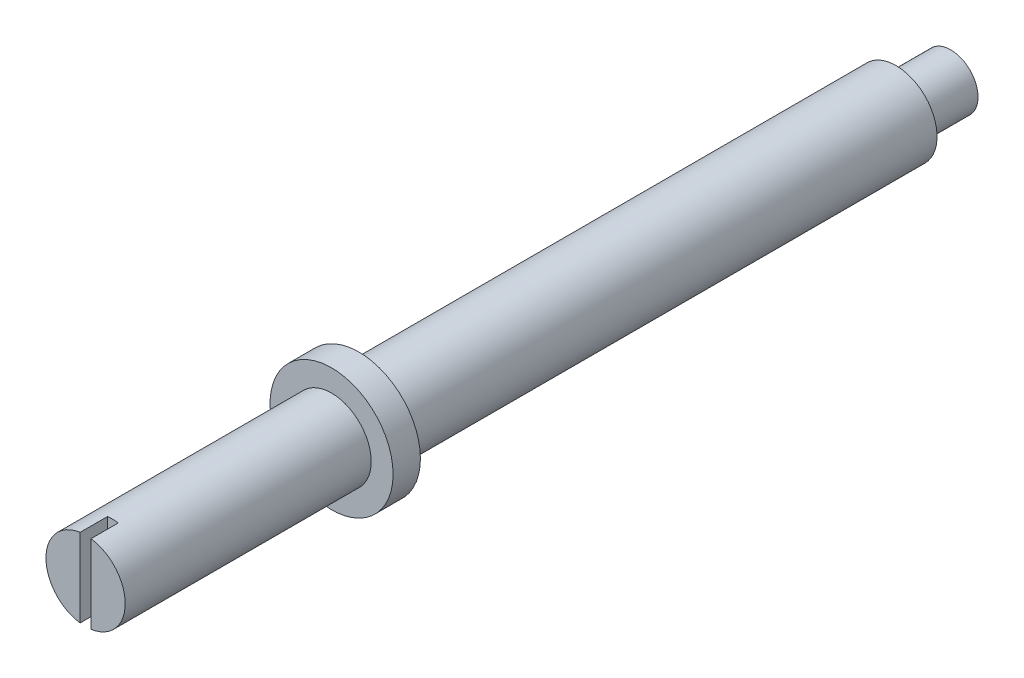
from build123d import *

# Parameters (mm, degrees)
SKETCH_1_R          = 1.5
EXTRUDE_1_DEPTH     = 22.65
SKETCH_2_R          = 1.45
EXTRUDE_2_DEPTH     = 9
CUT_EXTRUDE_1_DEPTH = 1
SKETCH_4_R          = 1.5
SKETCH_4_R_2        = 1
CUT_EXTRUDE_2_DEPTH = 2
SKETCH_5_R          = 2.25
EXTRUDE_3_DEPTH     = 1


with BuildPart() as part:
    # 草图1 → 凸台-拉伸1 (new body)
    with BuildSketch(Plane.XY):
        Circle(SKETCH_1_R)
    extrude(amount=EXTRUDE_1_DEPTH)

    # 草图2 → 凸台-拉伸2 (add)
    with BuildSketch(Plane.XY.offset(22.65)):
        Circle(SKETCH_2_R)
    extrude(amount=EXTRUDE_2_DEPTH)

    # 草图3 → 切除-拉伸1 (cut)
    with BuildSketch(Plane.XY.offset(31.65)):
        with BuildLine():
            Line((-0.2, -1.486606875), (-0.2, 1.486606875))
            ThreePointArc((-0.2, 1.486606875), (0, 1.5), (0.2, 1.486606875))
            Line((0.2, 1.486606875), (0.2, -1.486606875))
            ThreePointArc((0.2, -1.486606875), (0, -1.5), (-0.2, -1.486606875))
        make_face()
    extrude(amount=-CUT_EXTRUDE_1_DEPTH, mode=Mode.SUBTRACT)

    # 草图4 → 切除-拉伸2 (cut)
    with BuildSketch(Plane(origin=(0, 0, 0), x_dir=(-1, 0, 0), z_dir=(0, 0, -1))):
        Circle(SKETCH_4_R)
        Circle(SKETCH_4_R_2, mode=Mode.SUBTRACT)
    extrude(amount=-CUT_EXTRUDE_2_DEPTH, mode=Mode.SUBTRACT)

    # 草图5 → 凸台-拉伸3 (add)
    with BuildSketch(Plane.XY.offset(22.65)):
        Circle(SKETCH_5_R)
    extrude(amount=-EXTRUDE_3_DEPTH)


solid = part.part
